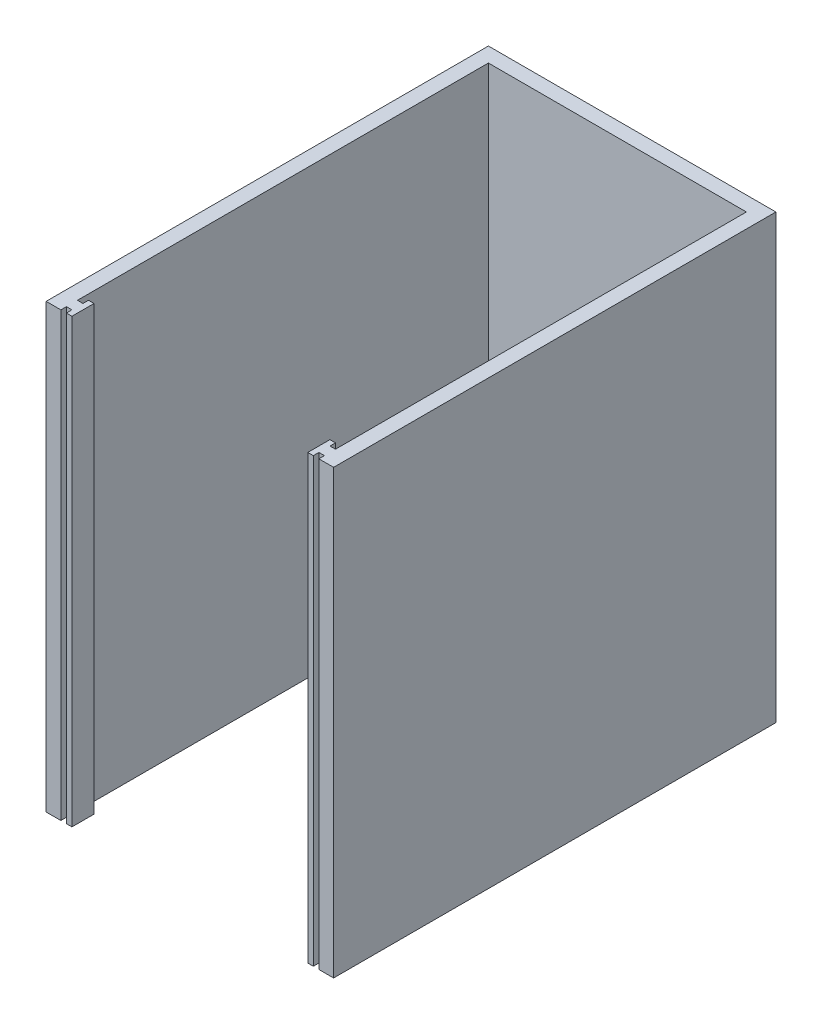
from build123d import *

# Parameters (mm, degrees)
BOSS_EXTRU_2_DEPTH = 120


with BuildPart() as part:
    # Esquisse1 → Boss.-Extru.2 (new body)
    with BuildSketch(Plane(origin=(0, 0, 0), x_dir=(1, 0, 0), z_dir=(0, 1, 0))):
        Polygon((74, -120), (78, -120), (78, 0), (0, 0), (0, -120), (4, -120), (4, -118.5), (5.5, -118.5), (5.5, -120), (7, -120), (7, -114), (5.5, -114), (5.5, -115.5), (4, -115.5), (4, -4), (74, -4), (74, -115.5), (72.5, -115.5), (72.5, -114), (71, -114), (71, -120), (72.5, -120), (72.5, -118.5), (74, -118.5), align=None)
    extrude(amount=BOSS_EXTRU_2_DEPTH)


solid = part.part
